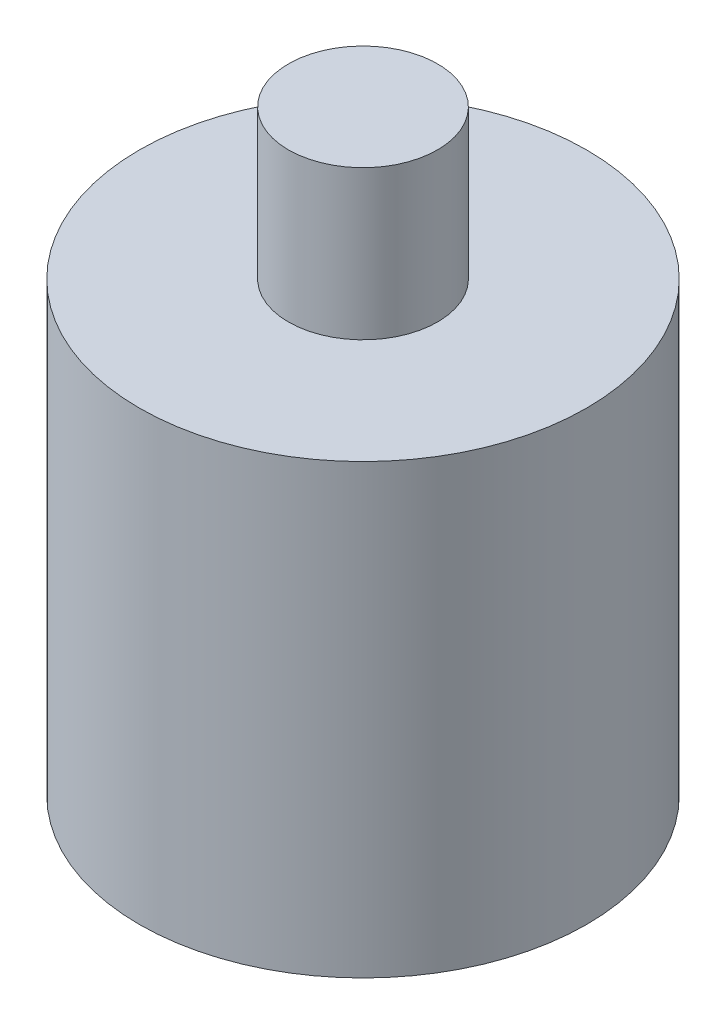
from build123d import *

# Parameters (mm, degrees)
SKETCH1_R           = 15
BOSS_EXTRUDE1_DEPTH = 30
SKETCH2_R           = 5
BOSS_EXTRUDE2_DEPTH = 10


with BuildPart() as part:
    # Sketch1 → Boss-Extrude1 (new body)
    with BuildSketch(Plane(origin=(0, 0, 0), x_dir=(1, 0, 0), z_dir=(0, 1, 0))):
        Circle(SKETCH1_R)
    extrude(amount=BOSS_EXTRUDE1_DEPTH)

    # Sketch2 → Boss-Extrude2 (add)
    with BuildSketch(Plane(origin=(0, 30, 0), x_dir=(1, 0, 0), z_dir=(0, 1, 0))):
        Circle(SKETCH2_R)
    extrude(amount=BOSS_EXTRUDE2_DEPTH)


solid = part.part
